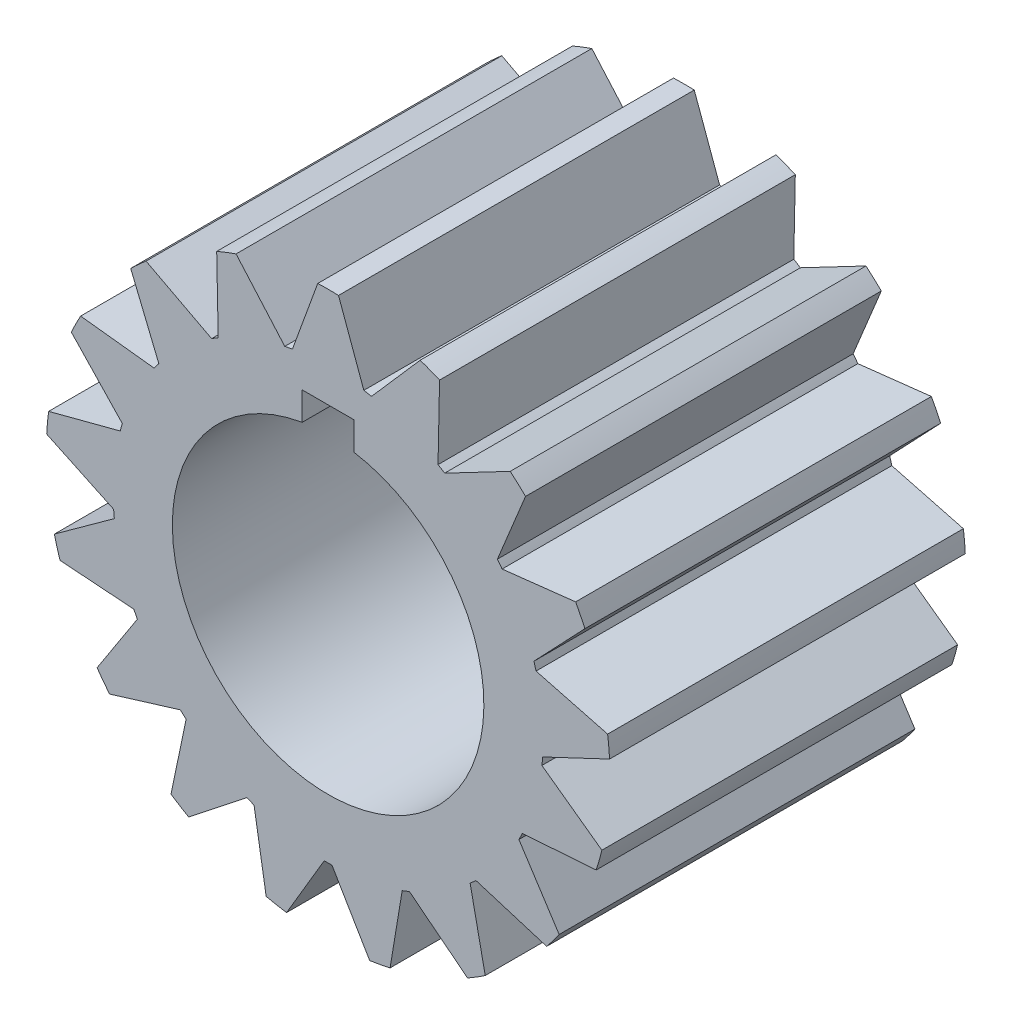
from build123d import *

# Parameters (mm, degrees)
BOSS_EXTRUDE1_DEPTH = 43.5102
CUT_EXTRUDE1_DEPTH  = 43.5102


with BuildPart() as part:
    # Sketch2 → Boss-Extrude1 (new body)
    with BuildSketch(Plane.XY):
        with BuildLine():
            Line((-4.366026501, 25.941944541), (-1.27, 34.448207442))
            ThreePointArc((-1.27, 34.448207442), (0, 34.47161), (1.27, 34.448207442))
            Line((1.27, 34.448207442), (4.366026501, 25.941944541))
            ThreePointArc((4.366026501, 25.941944541), (4.83385814, 25.858857079), (5.300112805, 25.767333549))
            Line((5.300112805, 25.767333549), (11.259888122, 32.580773709))
            ThreePointArc((11.259888122, 32.580773709), (12.452581833, 32.143819028), (13.628367585, 31.663219877))
            Line((13.628367585, 31.663219877), (13.442509735, 22.612952173))
            ThreePointArc((13.442509735, 22.612952173), (13.848735094, 22.366475142), (14.250442508, 22.11270138))
            Line((14.250442508, 22.11270138), (22.26906596, 26.31312595))
            ThreePointArc((22.26906596, 26.31312595), (23.223373486, 25.474827181), (24.14614861, 24.601939015))
            Line((24.14614861, 24.601939015), (20.703507542, 16.229955312))
            ThreePointArc((20.703507542, 16.229955312), (20.993263634, 15.8533768), (21.276170986, 15.471626358))
            Line((21.276170986, 15.471626358), (30.270683044, 16.491744725))
            ThreePointArc((30.270683044, 16.491744725), (30.857719866, 15.365318762), (31.402858467, 14.218029965))
            Line((31.402858467, 14.218029965), (25.168381933, 7.655013053))
            ThreePointArc((25.168381933, 7.655013053), (25.302535593, 7.199192074), (25.428434676, 6.741022466))
            Line((25.428434676, 6.741022466), (34.184076646, 4.443061991))
            ThreePointArc((34.184076646, 4.443061991), (34.324560189, 3.180638903), (34.418438279, 1.913897183))
            Line((34.418438279, 1.913897183), (26.234126882, -1.953781138))
            ThreePointArc((26.234126882, -1.953781138), (26.194559914, -2.427283433), (26.14644736, -2.899993864))
            Line((26.14644736, -2.899993864), (33.480721277, -8.205680884))
            ThreePointArc((33.480721277, -8.205680884), (33.155678459, -9.433603865), (32.785617282, -10.648718018))
            Line((32.785617282, -10.648718018), (23.756807626, -11.298706359))
            ThreePointArc((23.756807626, -11.298706359), (23.54886377, -11.725940863), (23.333237446, -12.149349953))
            Line((23.333237446, -12.149349953), (28.255608976, -19.746201087))
            ThreePointArc((28.255608976, -19.746201087), (27.508938632, -20.773786158), (26.724917, -21.773164845))
            Line((26.724917, -21.773164845), (18.07099986, -19.117678678))
            ThreePointArc((18.07099986, -19.117678678), (17.722763084, -19.440945003), (17.36874452, -19.757869009))
            Line((17.36874452, -19.757869009), (19.214420114, -28.619887416))
            ThreePointArc((19.214420114, -28.619887416), (18.14696421, -29.308353518), (17.054868589, -29.95702511))
            Line((17.054868589, -29.95702511), (9.944603428, -24.354702557))
            ThreePointArc((9.944603428, -24.354702557), (9.503105039, -24.530341795), (9.058506404, -24.697978373))
            Line((9.058506404, -24.697978373), (7.578217344, -33.628299361))
            ThreePointArc((7.578217344, -33.628299361), (6.334141716, -33.884665333), (5.081465671, -34.095023136))
            Line((5.081465671, -34.095023136), (0.475133198, -26.302488901))
            ThreePointArc((0.475133198, -26.302488901), (0, -26.30678), (-0.475133198, -26.302488901))
            Line((-0.475133198, -26.302488901), (-5.081465671, -34.095023136))
            ThreePointArc((-5.081465671, -34.095023136), (-6.334141716, -33.884665333), (-7.578217344, -33.628299361))
            Line((-7.578217344, -33.628299361), (-9.058506404, -24.697978373))
            ThreePointArc((-9.058506404, -24.697978373), (-9.503105039, -24.530341795), (-9.944603428, -24.354702557))
            Line((-9.944603428, -24.354702557), (-17.054868589, -29.95702511))
            ThreePointArc((-17.054868589, -29.95702511), (-18.14696421, -29.308353518), (-19.214420114, -28.619887416))
            Line((-19.214420114, -28.619887416), (-17.36874452, -19.757869009))
            ThreePointArc((-17.36874452, -19.757869009), (-17.722763084, -19.440945003), (-18.07099986, -19.117678678))
            Line((-18.07099986, -19.117678678), (-26.724917, -21.773164845))
            ThreePointArc((-26.724917, -21.773164845), (-27.508938632, -20.773786158), (-28.255608976, -19.746201087))
            Line((-28.255608976, -19.746201087), (-23.333237446, -12.149349953))
            ThreePointArc((-23.333237446, -12.149349953), (-23.54886377, -11.725940863), (-23.756807626, -11.298706359))
            Line((-23.756807626, -11.298706359), (-32.785617282, -10.648718018))
            ThreePointArc((-32.785617282, -10.648718018), (-33.155678459, -9.433603865), (-33.480721277, -8.205680884))
            Line((-33.480721277, -8.205680884), (-26.14644736, -2.899993864))
            ThreePointArc((-26.14644736, -2.899993864), (-26.194559914, -2.427283433), (-26.234126882, -1.953781138))
            Line((-26.234126882, -1.953781138), (-34.418438279, 1.913897183))
            ThreePointArc((-34.418438279, 1.913897183), (-34.324560189, 3.180638903), (-34.184076646, 4.443061991))
            Line((-34.184076646, 4.443061991), (-25.428434676, 6.741022466))
            ThreePointArc((-25.428434676, 6.741022466), (-25.302535593, 7.199192074), (-25.168381933, 7.655013053))
            Line((-25.168381933, 7.655013053), (-31.402858467, 14.218029965))
            ThreePointArc((-31.402858467, 14.218029965), (-30.857719866, 15.365318762), (-30.270683044, 16.491744725))
            Line((-30.270683044, 16.491744725), (-21.276170986, 15.471626358))
            ThreePointArc((-21.276170986, 15.471626358), (-20.993263634, 15.8533768), (-20.703507542, 16.229955312))
            Line((-20.703507542, 16.229955312), (-24.14614861, 24.601939015))
            ThreePointArc((-24.14614861, 24.601939015), (-23.223373486, 25.474827181), (-22.26906596, 26.31312595))
            Line((-22.26906596, 26.31312595), (-14.250442508, 22.11270138))
            ThreePointArc((-14.250442508, 22.11270138), (-13.848735094, 22.366475142), (-13.442509735, 22.612952173))
            Line((-13.442509735, 22.612952173), (-13.628367585, 31.663219877))
            ThreePointArc((-13.628367585, 31.663219877), (-12.452581833, 32.143819028), (-11.259888122, 32.580773709))
            Line((-11.259888122, 32.580773709), (-5.300112805, 25.767333549))
            ThreePointArc((-5.300112805, 25.767333549), (-4.83385814, 25.858857079), (-4.366026501, 25.941944541))
        make_face()
    extrude(amount=BOSS_EXTRUDE1_DEPTH)

    # Sketch4 → Cut-Extrude1 (cut)
    with BuildSketch(Plane.XY.offset(43.5102)):
        with BuildLine():
            Line((-3.175, 22.225), (3.175, 22.225))
            Line((3.175, 22.225), (3.175, 18.783553311))
            ThreePointArc((3.175, 18.783553311), (0, -19.05), (-3.175, 18.783553311))
            Line((-3.175, 18.783553311), (-3.175, 22.225))
        make_face()
    extrude(amount=-CUT_EXTRUDE1_DEPTH, mode=Mode.SUBTRACT)


solid = part.part
